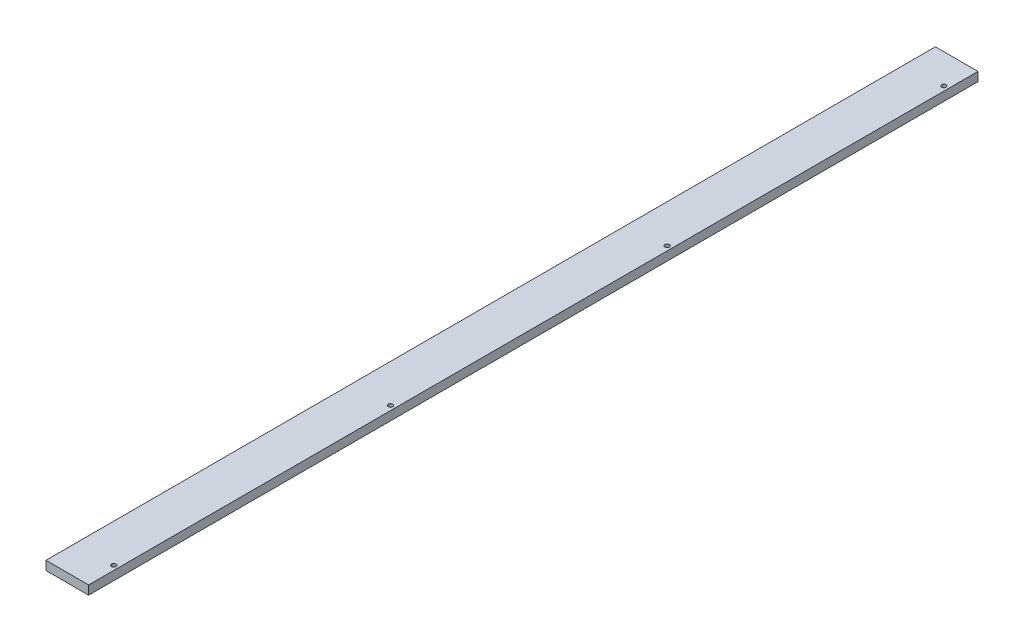
from build123d import *

# Parameters (mm, degrees)
SKETCH1_W           = 62
SKETCH1_H           = 1200
BOSS_EXTRUDE1_DEPTH = 12
SKETCH2_R           = 3
CUT_EXTRUDE1_DEPTH  = 22
SKETCH3_W           = 8.753853417
SKETCH3_H           = 1524
CUT_EXTRUDE2_DEPTH  = 20


with BuildPart() as part:
    # Sketch1 → Boss-Extrude1 (new body)
    with BuildSketch(Plane(origin=(0, 0, 0), x_dir=(1, 0, 0), z_dir=(0, 1, 0))):
        with Locations((31, 600)):
            Rectangle(SKETCH1_W, SKETCH1_H)
    extrude(amount=BOSS_EXTRUDE1_DEPTH)

    # Sketch2 → Cut-Extrude1 (cut)
    with BuildSketch(Plane(origin=(0, 12, 0), x_dir=(1, 0, 0), z_dir=(0, 1, 0))):
        with Locations((56, 40)):
            Circle(SKETCH2_R)
        with Locations((56, 413.333333333)):
            Circle(SKETCH2_R)
        with Locations((56, 786.666666667)):
            Circle(SKETCH2_R)
        with Locations((56, 1160)):
            Circle(SKETCH2_R)
    extrude(amount=-CUT_EXTRUDE1_DEPTH, mode=Mode.SUBTRACT)

    # Sketch3 → Cut-Extrude2 (cut)
    with BuildSketch(Plane(origin=(0, 12, 0), x_dir=(1, 0, 0), z_dir=(0, 1, 0))):
        with Locations((0.123073291, 762)):
            Rectangle(SKETCH3_W, SKETCH3_H)
    extrude(amount=-CUT_EXTRUDE2_DEPTH, mode=Mode.SUBTRACT)


solid = part.part
